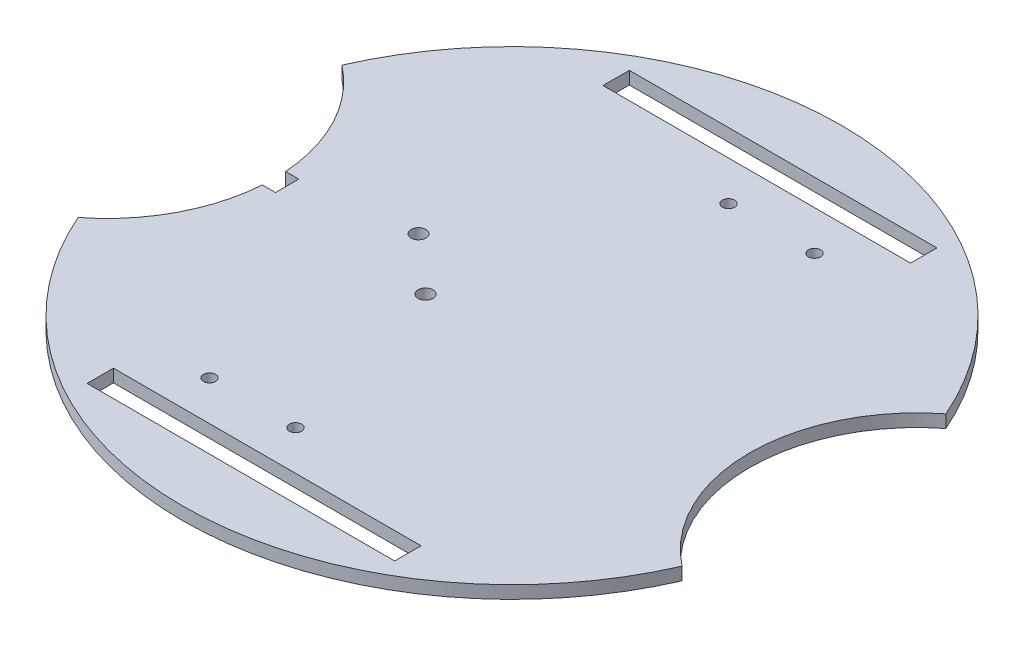
from build123d import *

# Parameters (mm, degrees)
SKETCH1_R           = 75
BOSS_EXTRUDE1_DEPTH = 2.9
SKETCH2_W           = 70
SKETCH2_H           = 6
SKETCH2_R           = 1.4
CUT_EXTRUDE1_DEPTH  = 10
SKETCH3_R           = 1.7
CUT_EXTRUDE3_DEPTH  = 10


with BuildPart() as part:
    # Sketch1 → Boss-Extrude1 (new body)
    with BuildSketch(Plane(origin=(0, 0, 0), x_dir=(1, 0, 0), z_dir=(0, 1, 0))):
        with Locations(Location((0, 0, 0), (0, 0, 270))):
            Circle(SKETCH1_R)
    extrude(amount=BOSS_EXTRUDE1_DEPTH)

    # Sketch2 → Cut-Extrude1 (cut)
    with BuildSketch(Plane(origin=(0, 2.9, 0), x_dir=(1, 0, 0), z_dir=(0, 1, 0))):
        with Locations((0, -58.709242105)):
            Rectangle(SKETCH2_W, SKETCH2_H)
        with Locations((0, 58.709242105)):
            Rectangle(SKETCH2_W, SKETCH2_H)
        with BuildLine():
            ThreePointArc((-68.72850121, -30.023209712), (-54.08520342, 0), (-68.72850121, 30.023209712))
            ThreePointArc((-68.72850121, 30.023209712), (-75, 0), (-68.72850121, -30.023209712))
        make_face()
        with BuildLine():
            ThreePointArc((68.72850121, -30.023209712), (75, 0), (68.72850121, 30.023209712))
            ThreePointArc((68.72850121, 30.023209712), (54.08520342, 0), (68.72850121, -30.023209712))
        make_face()
        with Locations(Location((-22.14, -46.709242105, 0), (0, 0, 270))):
            Circle(SKETCH2_R)
        with Locations(Location((-2.56, -46.709242105, 0), (0, 0, 270))):
            Circle(SKETCH2_R)
        with Locations(Location((22.14, 46.709242105, 0), (0, 0, 270))):
            Circle(SKETCH2_R)
        with Locations(Location((2.56, 46.709242105, 0), (0, 0, 270))):
            Circle(SKETCH2_R)
    extrude(amount=-CUT_EXTRUDE1_DEPTH, mode=Mode.SUBTRACT)

    # Sketch3 → Cut-Extrude3 (cut)
    with BuildSketch(Plane(origin=(0, 2.9, 0), x_dir=(1, 0, 0), z_dir=(0, 1, 0))):
        with Locations(Location((-26.78520342, 5.5, 0), (0, 0, 270))):
            Circle(SKETCH3_R)
        with Locations(Location((-14.08520342, -5.6, 0), (0, 0, 270))):
            Circle(SKETCH3_R)
        with BuildLine():
            Line((-51.177473943, 2.65), (-54.177473943, 2.65))
            ThreePointArc((-54.177473943, 2.65), (-54.08520342, 0), (-54.177473943, -2.65))
            Line((-54.177473943, -2.65), (-51.177473943, -2.65))
            Line((-51.177473943, -2.65), (-51.177473943, 2.65))
        make_face()
    extrude(amount=-CUT_EXTRUDE3_DEPTH, mode=Mode.SUBTRACT)


solid = part.part
